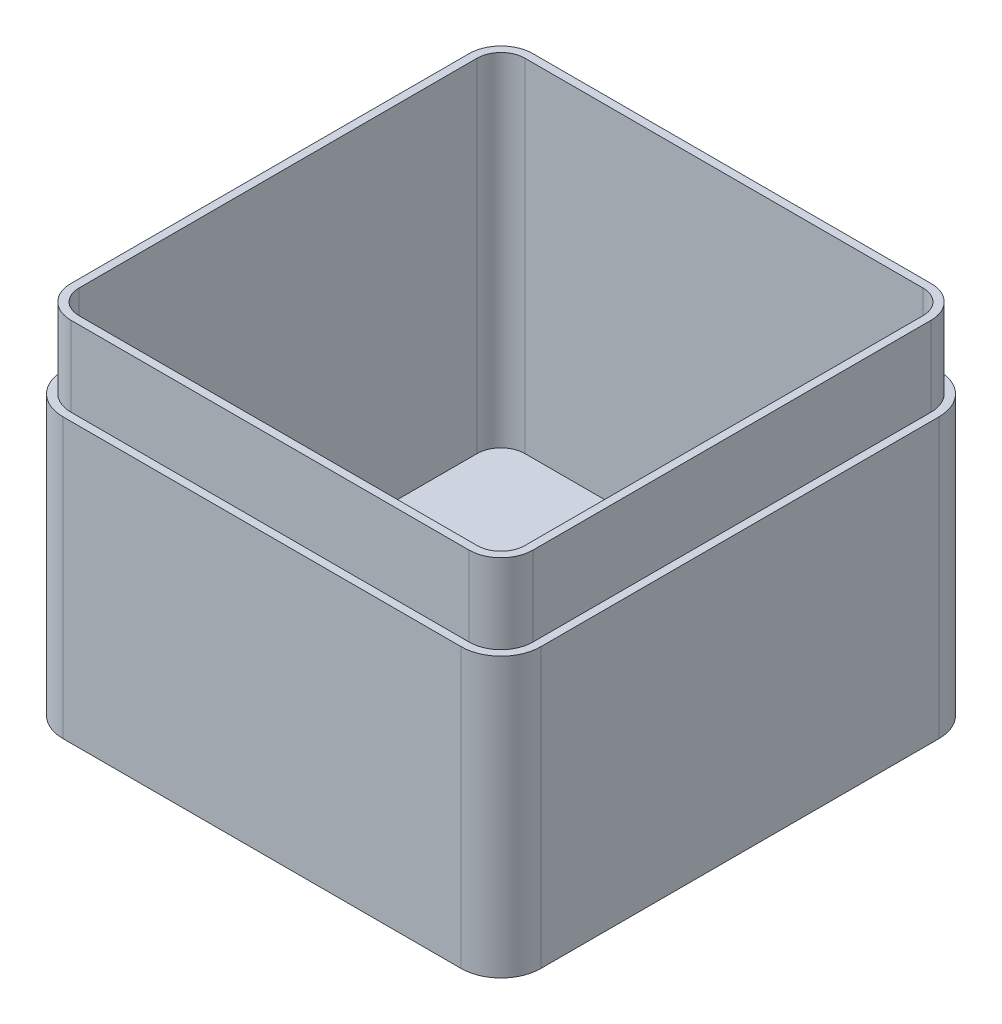
from build123d import *

# Parameters (mm, degrees)
SKETCH1_W           = 120
SKETCH1_H           = 120
BOSS_EXTRUDE1_DEPTH = 90
FILLET1_R           = 10
SHELL1_T            = -4
CUT_EXTRUDE1_DEPTH  = 20


with BuildPart() as part:
    # Sketch1 → Boss-Extrude1 (new body)
    with BuildSketch(Plane(origin=(0, 0, 0), x_dir=(1, 0, 0), z_dir=(0, 1, 0))):
        Rectangle(SKETCH1_W, SKETCH1_H)
    extrude(amount=BOSS_EXTRUDE1_DEPTH)

    # Fillet1
    fillet1_edges = [part.edges().sort_by_distance(p)[0] for p in [
        (60, 45, 60),
        (-60, 45, 60),
        (-60, 45, -60),
        (60, 45, -60),
    ]]
    fillet(fillet1_edges, radius=FILLET1_R)

    # Shell1
    shell1_openings = [part.faces().sort_by_distance(p)[0] for p in [
        (0, 90, 0),
    ]]
    offset(amount=SHELL1_T, openings=shell1_openings, kind=Kind.INTERSECTION)

    # Sketch6 → Cut-Extrude1 (cut)
    with BuildSketch(Plane(origin=(0, 90, 0), x_dir=(1, 0, 0), z_dir=(0, 1, 0))):
        with BuildLine():
            Line((50, 60), (-50, 60))
            ThreePointArc((-50, 60), (-57.071067812, 57.071067812), (-60, 50))
            Line((-60, 50), (-60, -50))
            ThreePointArc((-60, -50), (-57.071067812, -57.071067812), (-50, -60))
            Line((-50, -60), (50, -60))
            ThreePointArc((50, -60), (57.071067812, -57.071067812), (60, -50))
            Line((60, -50), (60, 50))
            ThreePointArc((60, 50), (57.071067812, 57.071067812), (50, 60))
        make_face()
        with BuildLine():
            Line((50, 58), (-50, 58))
            ThreePointArc((-50, 58), (-55.656854249, 55.656854249), (-58, 50))
            Line((-58, 50), (-58, -50))
            ThreePointArc((-58, -50), (-55.656854249, -55.656854249), (-50, -58))
            Line((-50, -58), (50, -58))
            ThreePointArc((50, -58), (55.656854249, -55.656854249), (58, -50))
            Line((58, -50), (58, 50))
            ThreePointArc((58, 50), (55.656854249, 55.656854249), (50, 58))
        make_face(mode=Mode.SUBTRACT)
    extrude(amount=-CUT_EXTRUDE1_DEPTH, mode=Mode.SUBTRACT)


solid = part.part
